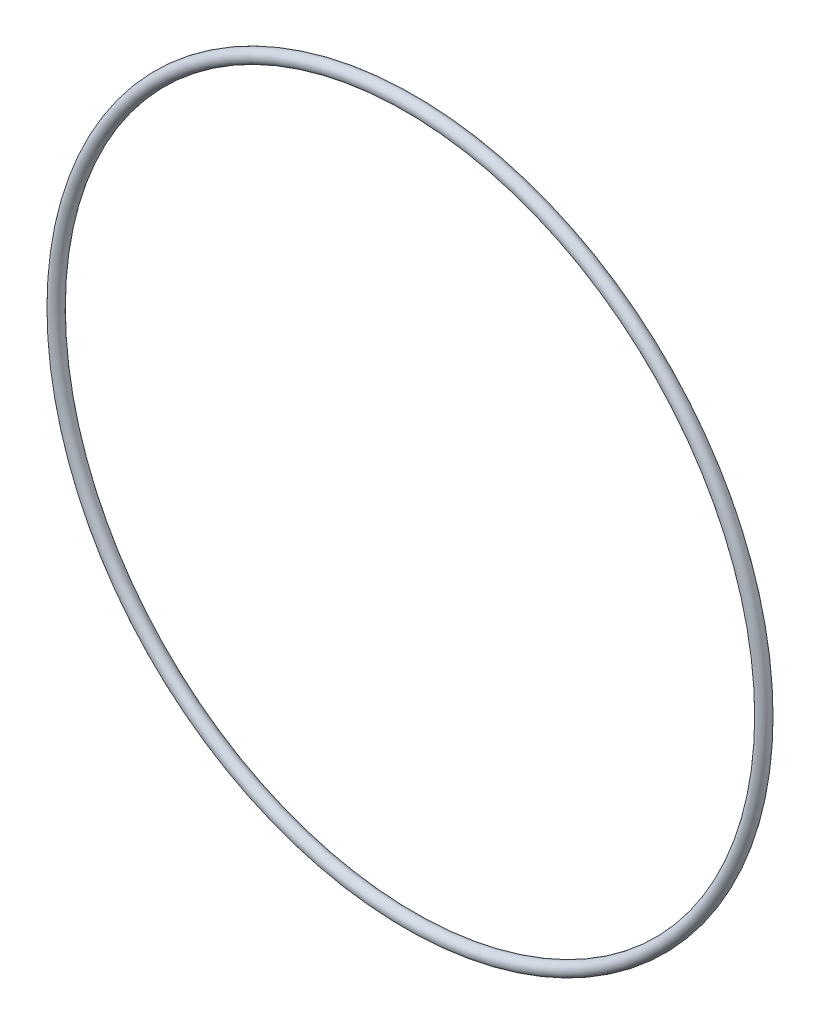
from build123d import *

# Parameters (mm, degrees)
SKETCH1_R = 0.889


with BuildPart() as part:
    # Sketch1 → Revolve1 (revolve)
    with BuildSketch(Plane(origin=(0, 0, 0), x_dir=(0, -1, 0), z_dir=(1, 0, 0))):
        with Locations((48.3743, 0)):
            Circle(SKETCH1_R)
    revolve(axis=Axis((0, 0, 0.889), (0, 0, -1)))


solid = part.part
